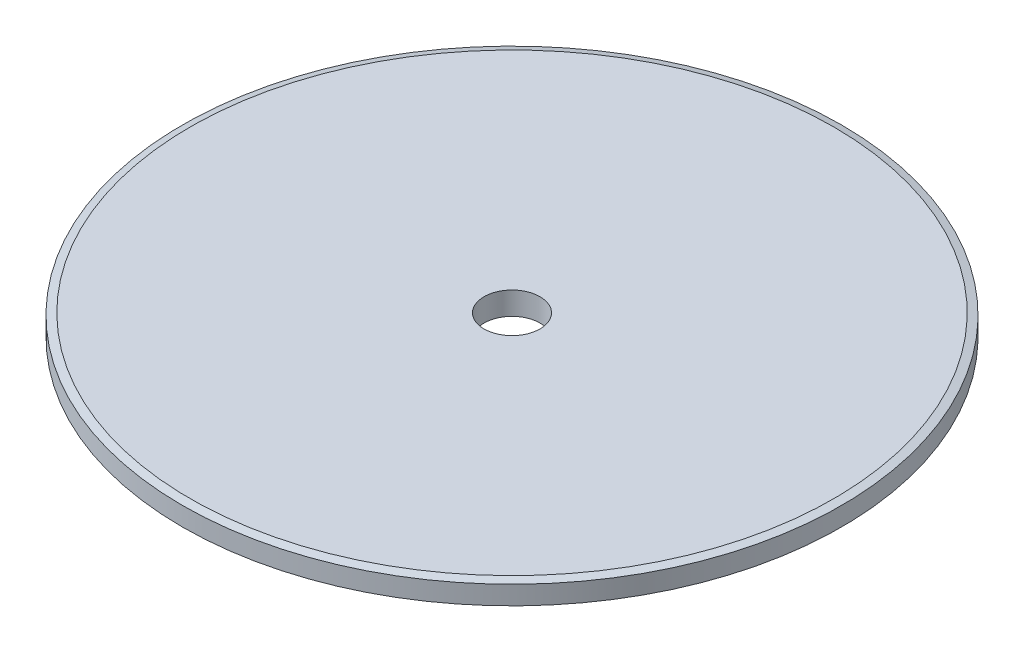
from build123d import *

# Parameters (mm, degrees)
SKETCH_1_W               = 70.7
SKETCH_1_H               = 4.9
CHAMFER_1_SIZE           = 1.645
CHAMFER_1_SIZE2          = 0.440776422
CHAMFER_2_SIZE           = 1.645
CHAMFER_2_SIZE2          = 0.440776422
SKETCH_2_R               = 6
CUT_EXTRUDE_3_DEPTH      = 1
CUT_EXTRUDE_3_DEPTH_BACK = 5.9


with BuildPart() as part:
    # Эскиз1 → Повернуть2 (revolve)
    with BuildSketch(Plane.XY):
        with Locations((35.35, 2.45)):
            Rectangle(SKETCH_1_W, SKETCH_1_H)
    revolve(axis=Axis((0, 4.9, 0), (0, -1, 0)))

    # Фаска1
    chamfer_1_edges = [part.edges().sort_by_distance(p)[0] for p in [
        (-70.7, 4.9, 0),
    ]]
    chamfer_1_side = [part.faces().sort_by_distance(p)[0] for p in [
        (0, 4.9, 0),
    ]]
    chamfer(chamfer_1_edges, length=CHAMFER_1_SIZE, length2=CHAMFER_1_SIZE2, reference=chamfer_1_side[0])

    # Фаска2
    chamfer_2_edges = [part.edges().sort_by_distance(p)[0] for p in [
        (-70.7, 0, 0),
    ]]
    chamfer_2_side = [part.faces().sort_by_distance(p)[0] for p in [
        (0, 0, 0),
    ]]
    chamfer(chamfer_2_edges, length=CHAMFER_2_SIZE, length2=CHAMFER_2_SIZE2, reference=chamfer_2_side[0])

    # Эскиз2 → Вырез-Вытянуть3 (cut, two sides)
    with BuildSketch(Plane(origin=(0, 0, 0), x_dir=(-1, 0, 0), z_dir=(0, -1, 0))) as cut_extrude_3_sk:
        Circle(SKETCH_2_R)
    extrude(amount=CUT_EXTRUDE_3_DEPTH, mode=Mode.SUBTRACT)
    extrude(cut_extrude_3_sk.sketch, amount=-CUT_EXTRUDE_3_DEPTH_BACK, mode=Mode.SUBTRACT)


solid = part.part
